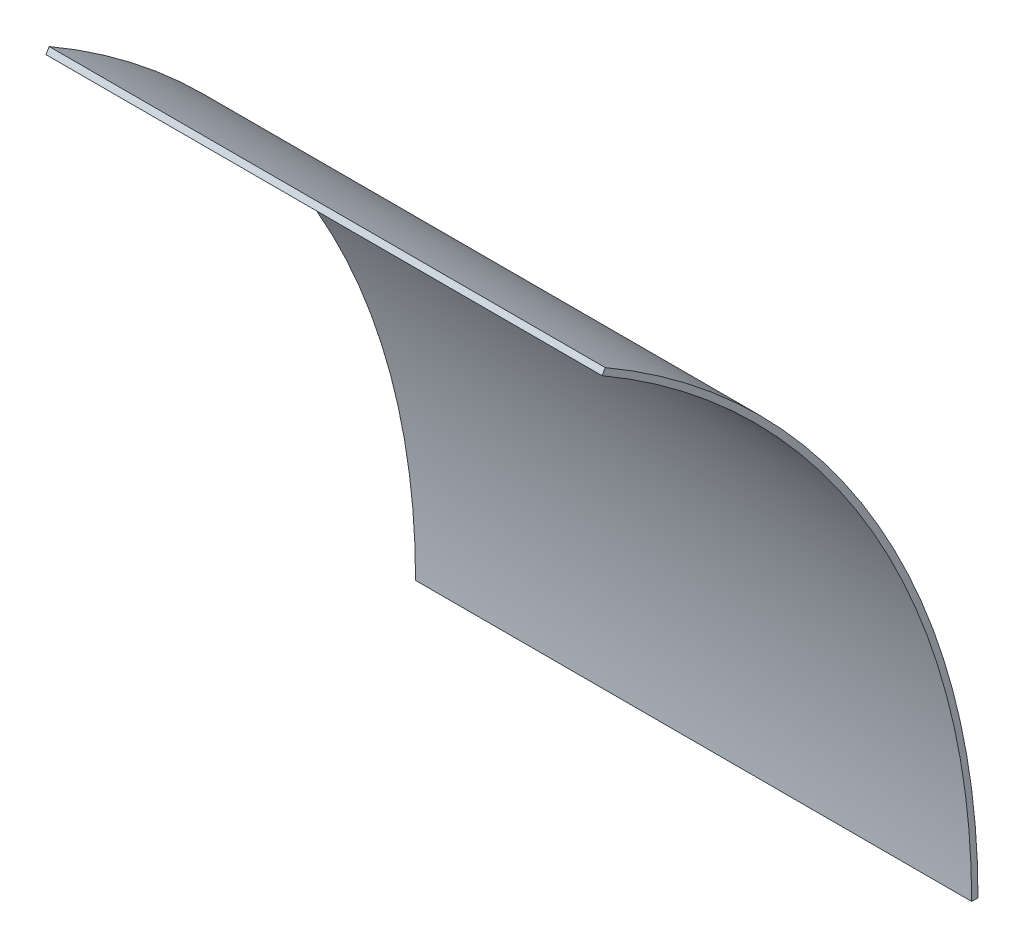
from build123d import *

# Parameters (mm, degrees)
BOSS_EXTRUDE1_DEPTH = 139.7


with BuildPart() as part:
    # Sketch1 → Boss-Extrude1 (new body)
    with BuildSketch(Plane(origin=(0, 0, 0), x_dir=(0, 0, -1), z_dir=(1, 0, 0))):
        with BuildLine():
            Line((93.63075, 162.173216151), (92.837, 160.798400822))
            ThreePointArc((92.837, 160.798400822), (160.798400822, 92.837), (185.674, 0))
            Line((185.674, 0), (187.2615, 0))
            ThreePointArc((187.2615, 0), (162.173216151, 93.63075), (93.63075, 162.173216151))
        make_face()
    extrude(amount=BOSS_EXTRUDE1_DEPTH)


solid = part.part
